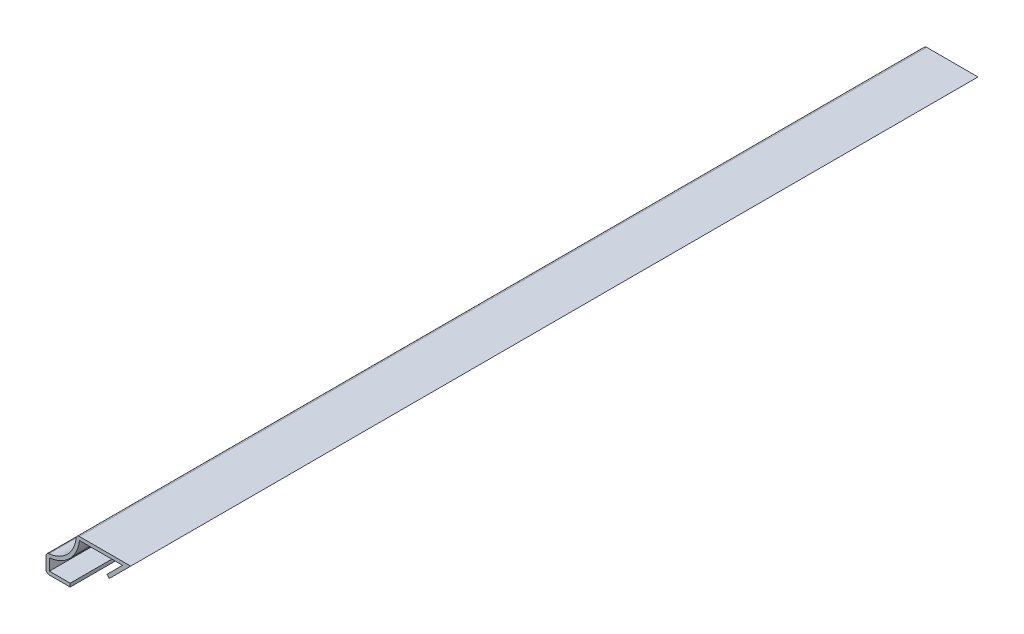
from build123d import *

# Parameters (mm, degrees)
EXTRUDE_THIN1_DEPTH = 222.25
FILLET1_R           = 0.889


with BuildPart() as part:
    # Sketch1 → Extrude-Thin1 (new body)
    with BuildSketch(Plane.XY):
        with BuildLine():
            Line((0, 0), (-6.35, 0))
            Line((-6.35, 0), (-6.35, 4.7625))
            ThreePointArc((-6.35, 4.7625), (-0.737339924, 7.087339924), (1.5875, 12.7))
            Line((1.5875, 12.7), (15.875, 12.7))
            Line((15.875, 12.7), (10.262339924, 7.087339924))
            Line((10.262339924, 7.087339924), (9.633721996, 7.715957853))
            Line((9.633721996, 7.715957853), (13.728764143, 11.811))
            Line((13.728764143, 11.811), (2.431616096, 11.811))
            ThreePointArc((2.431616096, 11.811), (-0.108721996, 6.458721996), (-5.461, 3.918383904))
            Line((-5.461, 3.918383904), (-5.461, 0.889))
            Line((-5.461, 0.889), (0, 0.889))
            Line((0, 0.889), (0, 0))
        make_face()
    extrude(amount=-EXTRUDE_THIN1_DEPTH)

    # Fillet1
    fillet1_edges = [part.edges().sort_by_distance(p)[0] for p in [
        (-6.35, 0, -111.125),
        (-6.35, 4.7625, -111.125),
        (1.5875, 12.7, -111.125),
    ]]
    fillet(fillet1_edges, radius=FILLET1_R)


solid = part.part
